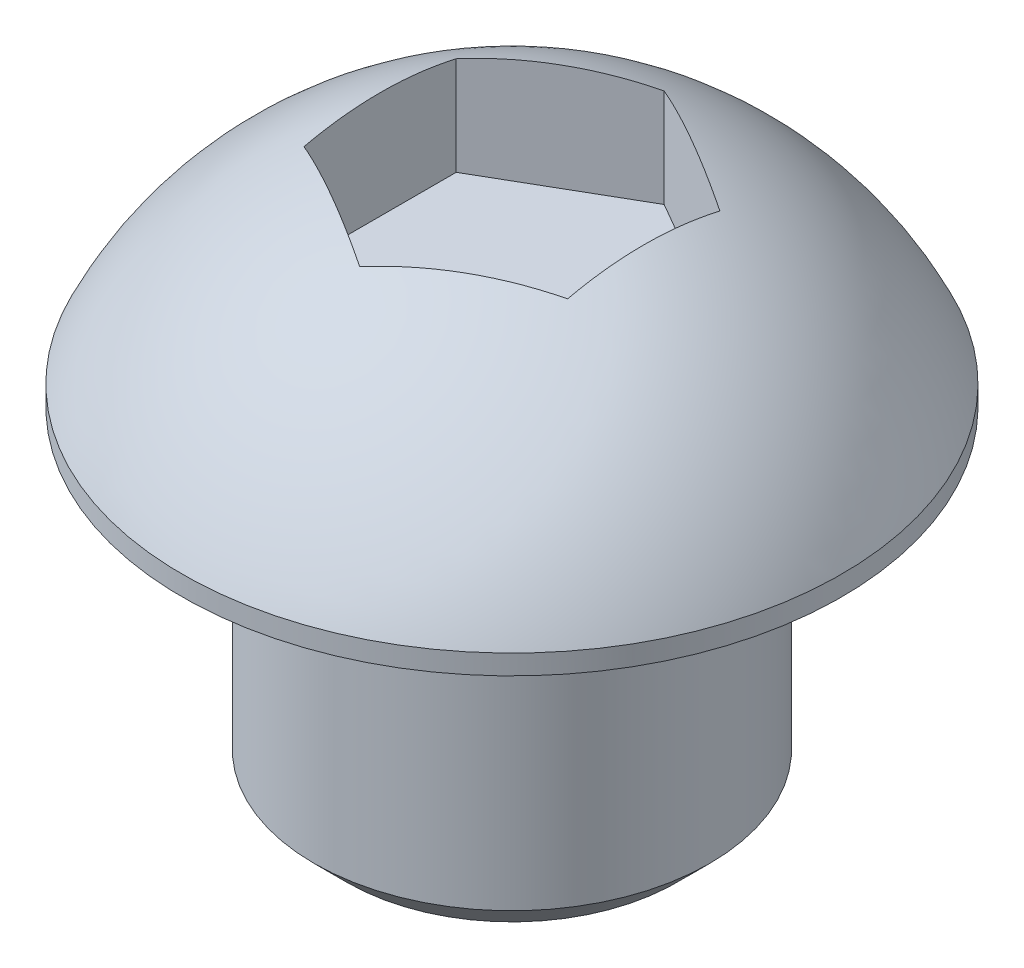
from build123d import *

# Parameters (mm, degrees)
SKETCH1_R           = 3
BOSS_EXTRUDE3_DEPTH = 5
CHAMFER2_SIZE       = 0.5
CUT_EXTRUDE2_DEPTH  = 2


with BuildPart() as part:
    # Sketch1 → Boss-Extrude3 (new body)
    with BuildSketch(Plane(origin=(0, 0, 0), x_dir=(1, 0, 0), z_dir=(0, 1, 0))):
        Circle(SKETCH1_R)
    extrude(amount=-BOSS_EXTRUDE3_DEPTH)

    # Sketch3 → Revolve2 (revolve)
    with BuildSketch(Plane.XY):
        with BuildLine():
            Line((-5, 0), (-5, 0.3))
            ThreePointArc((-5, 0.3), (-2.969144584, 2.634024216), (0, 3.503635162))
            Line((0, 3.503635162), (0, 0))
            Line((0, 0), (-5, 0))
        make_face()
    revolve(axis=Axis((0, -2, 0), (0, 1, 0)))

    # Chamfer2
    chamfer2_edges = [part.edges().sort_by_distance(p)[0] for p in [
        (-3, -5, 0),
    ]]
    chamfer(chamfer2_edges, length=CHAMFER2_SIZE)

    # Sketch4 → Cut-Extrude2 (cut)
    with BuildSketch(Plane(origin=(0, 3.503635162, 0), x_dir=(1, 0, 0), z_dir=(0, 1, 0))):
        Polygon((0, 2.309401077), (-2, 1.154700538), (-2, -1.154700538), (0, -2.309401077), (2, -1.154700538), (2, 1.154700538), align=None)
    extrude(amount=-CUT_EXTRUDE2_DEPTH, mode=Mode.SUBTRACT)


solid = part.part
